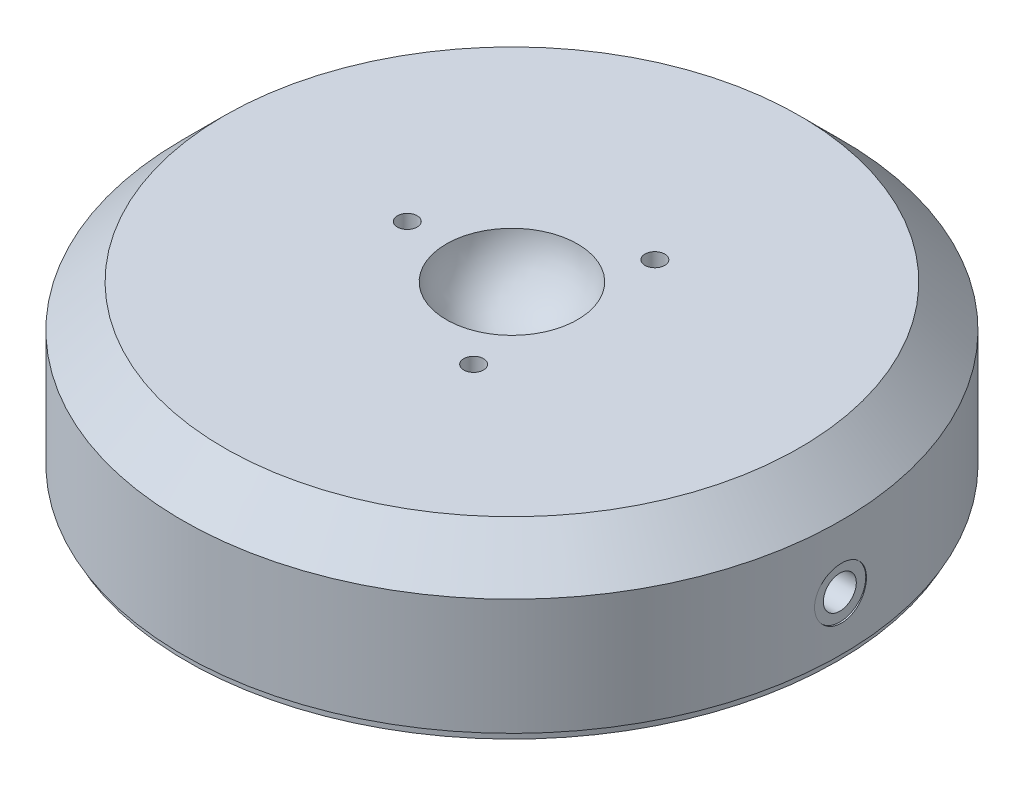
from build123d import *

# Parameters (mm, degrees)
M5X0_8_TAPPED_HOLE1_D                               = 4.2
M5X0_8_TAPPED_HOLE1_DEPTH                           = 46.99
M5X0_8_TAPPED_HOLE1_CBORE_D                         = 5
M5X0_8_TAPPED_HOLE1_CBORE_DEPTH                     = 7.62
M5X0_8_TAPPED_HOLE1_TIP                             = 1.2618073
CIRPATTERN1_COUNT                                   = 3
CBORE_FOR_00_BINDING_HEAD_MACHINE_SCREW_D           = 1.397
CBORE_FOR_00_BINDING_HEAD_MACHINE_SCREW_DEPTH       = 6.35
CBORE_FOR_00_BINDING_HEAD_MACHINE_SCREW_CBORE_D     = 7.874
CBORE_FOR_00_BINDING_HEAD_MACHINE_SCREW_CBORE_DEPTH = 0.254
CBORE_FOR_00_BINDING_HEAD_MACHINE_SCREW_TIP         = 0.419701142
SKETCH2_R                                           = 49.3395
EXTRUDE1_DEPTH                                      = 1.2192


with BuildPart() as part:
    # Sketch1 → Revolve1 (revolve)
    with BuildSketch(Plane.XY, mode=Mode.PRIVATE) as revolve1_sk:
        with BuildLine():
            Line((0, 0), (49.9999, 0))
            Line((49.9999, 0), (49.9999, 17.6276))
            Line((49.9999, 17.6276), (43.6499, 23.9776))
            Line((43.6499, 23.9776), (9.955892816, 23.9776))
            ThreePointArc((9.955892816, 23.9776), (7.139407653, 17.980689326), (1.1938, 15.057458932))
            Line((1.1938, 15.057458932), (1.1938, 14.5796))
            Line((1.1938, 14.5796), (0, 14.5796))
            Line((0, 14.5796), (0, 0))
        make_face()
    revolve(revolve1_sk.sketch.rotate(Axis((0, 23.9776, 0), (0, -1, 0)), 180), axis=Axis((0, 23.9776, 0), (0, -1, 0)))  # turned: the seam where the file's is

    # M5x0.8 Tapped Hole1
    with Locations(Plane(origin=(49.9999, 8.0772, 0), x_dir=(0, 0, 1), z_dir=(1, 0, 0))):
        with Locations((0, 0)):
            CounterBoreHole(M5X0_8_TAPPED_HOLE1_D / 2, M5X0_8_TAPPED_HOLE1_CBORE_D / 2, M5X0_8_TAPPED_HOLE1_CBORE_DEPTH, depth=M5X0_8_TAPPED_HOLE1_DEPTH)
            with Locations((0, 0, -(M5X0_8_TAPPED_HOLE1_DEPTH + M5X0_8_TAPPED_HOLE1_TIP / 2))):  # 118° drill point
                Cone(0, M5X0_8_TAPPED_HOLE1_D / 2, M5X0_8_TAPPED_HOLE1_TIP, mode=Mode.SUBTRACT)

    # Sketch5 → M3x0.5 Tapped Hole1 (revolve, cut)
    with BuildSketch(Plane(origin=(-15.875, 23.9776, 0), x_dir=(0, 0, 1), z_dir=(1, 0, 0))):
        Polygon((0, 0), (0, 10.403075774), (1.25, 9.652), (1.25, 5.9944), (1.5, 5.9944), (1.5, 0), align=None)
    m3x0_5_tapped_hole1 = revolve(axis=Axis((-15.875, 30.3276, 0), (0, -1, 0)), mode=Mode.SUBTRACT)

    # CirPattern1: M3x0.5 Tapped Hole1 ×3 about axis
    cirpattern1_axis = Axis((0, 0, 0), (0, 1, 0))
    for i in range(1, CIRPATTERN1_COUNT):
        add(m3x0_5_tapped_hole1.rotate(cirpattern1_axis, i * 360 / CIRPATTERN1_COUNT), mode=Mode.SUBTRACT)

    # CBORE for #00 Binding Head Machine Screw1
    with Locations(Plane(origin=(49.9999, 8.0772, 0), x_dir=(0, 0, 1), z_dir=(1, 0, 0))):
        with Locations((0, 0)):
            CounterBoreHole(CBORE_FOR_00_BINDING_HEAD_MACHINE_SCREW_D / 2, CBORE_FOR_00_BINDING_HEAD_MACHINE_SCREW_CBORE_D / 2, CBORE_FOR_00_BINDING_HEAD_MACHINE_SCREW_CBORE_DEPTH, depth=CBORE_FOR_00_BINDING_HEAD_MACHINE_SCREW_DEPTH)
            with Locations((0, 0, -(CBORE_FOR_00_BINDING_HEAD_MACHINE_SCREW_DEPTH + CBORE_FOR_00_BINDING_HEAD_MACHINE_SCREW_TIP / 2))):  # 118° drill point
                Cone(0, CBORE_FOR_00_BINDING_HEAD_MACHINE_SCREW_D / 2, CBORE_FOR_00_BINDING_HEAD_MACHINE_SCREW_TIP, mode=Mode.SUBTRACT)

    # Sketch2 → Extrude1 (add)
    with BuildSketch(Plane.XZ):
        with Locations(Location((0, 0, 0), (0, 0, 180))):  # turned: the seam where the file's is
            Circle(SKETCH2_R)
    extrude(amount=EXTRUDE1_DEPTH)


solid = part.part
